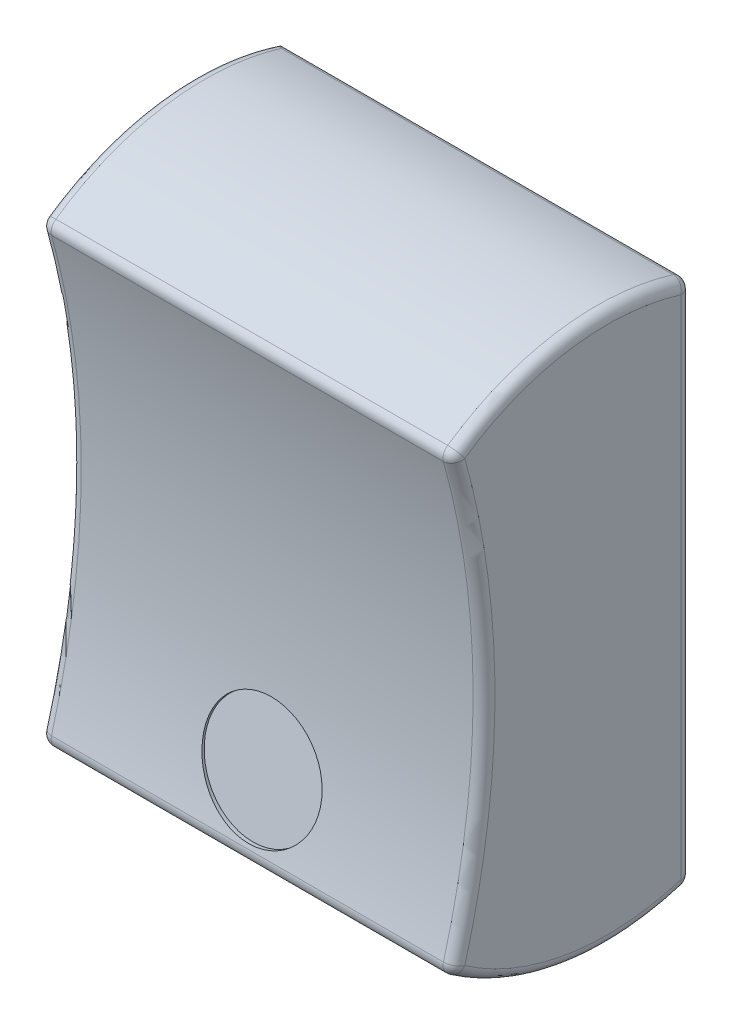
from build123d import *

# Parameters (mm, degrees)
BOSS_EXTRUDE2_DEPTH     = 9.5
FILLET1_R               = 0.5
SKETCH3_R               = 2.71
CUT_EXTRUDE1_DEPTH      = 5.448751278
CUT_EXTRUDE1_DEPTH_BACK = 0.1


with BuildPart() as part:
    # Sketch2 → Boss-Extrude2 (new body, symmetric)
    with BuildSketch(Plane(origin=(0, 0, 0), x_dir=(0, 0, -1), z_dir=(1, 0, 0))):
        with BuildLine():
            Line((0, 12), (0, -12))
            ThreePointArc((0, -12), (-5.710285596, -12.497714363), (-11, -10.29))
            ThreePointArc((-11, -10.29), (-9.540341867, 0), (-11, 10.29))
            ThreePointArc((-11, 10.29), (-5.710285596, 12.497714363), (0, 12))
        make_face()
    extrude(amount=BOSS_EXTRUDE2_DEPTH, both=True)

    # Fillet1
    fillet1_edges = [part.edges().sort_by_distance(p)[0] for p in [
        (9.5, 12.497714363, 5.710285596),
        (9.5, 0, 9.540341867),
        (9.5, -12.497714363, 5.710285596),
        (-9.5, 0, 9.540341867),
        (-9.5, 12.497714363, 5.710285596),
        (-9.5, -12.497714363, 5.710285596),
        (0, -10.29, 11),
        (0, 10.29, 11),
        (0, 12, 0),
        (0, -12, 0),
        (9.5, 0, 0),
    ]]
    fillet(fillet1_edges, radius=FILLET1_R)

    # Sketch3 → Cut-Extrude1 (cut, two sides)
    with BuildSketch(Plane(origin=(0, 1.657226633, 8.525691928), x_dir=(-1, 0, 0), z_dir=(0, 0.190808995, 0.981627183))) as cut_extrude1_sk:
        with Locations((0, 8.947950155)):
            Circle(SKETCH3_R)
    extrude(amount=CUT_EXTRUDE1_DEPTH, mode=Mode.SUBTRACT)
    extrude(cut_extrude1_sk.sketch, amount=-CUT_EXTRUDE1_DEPTH_BACK, mode=Mode.SUBTRACT)


solid = part.part
